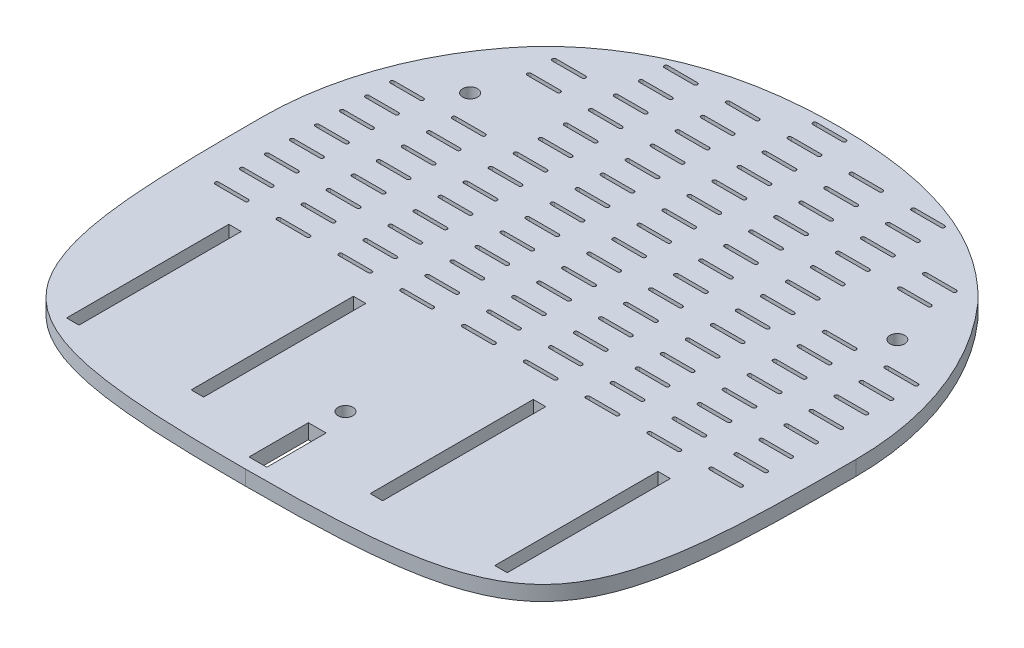
from build123d import *

# Parameters (mm, degrees)
BASE_DEPTH           = 6.35
EMPTYSPACETRIM_DEPTH = 185.858976792
SKETCH8_W            = 5.334
SKETCH8_H            = 69.446
SKETCH8_W_2          = 7.62
SKETCH8_H_2          = 25.4
SKETCH8_H_3          = 69.827
MOTORCUT_DEPTH       = 185.858976792
SKETCH11_R           = 3.175
SCREWCUT_DEPTH       = 185.858976792
CUT_EXTRUDE1_DEPTH   = 185.858976792
LPATTERN1_COUNT      = 9
LPATTERN1_PITCH      = 26.4541
LPATTERN1_COUNT_DIR2 = 15
LPATTERN1_PITCH_DIR2 = 10.7188


with BuildPart() as part:
    # Sketch1 → Base (new body)
    with BuildSketch(Plane(origin=(0, 0, 0), x_dir=(1, 0, 0), z_dir=(0, 1, 0))):
        with BuildLine():
            ThreePointArc((127, 0), (0, 127), (-127, 0))
            add(Edge.make_bspline(
                [(-127, 0), (-127, -50.624671912), (-125.847104384, -127.403215469), (-59.089145197, -134.177191606), (0, -134.177191606)],
                knots=[0, 0, 0, 0, 0.496988082, 1, 1, 1, 1], degree=3))
            add(Edge.make_bspline(
                [(127, 0), (127, -50.624671912), (125.847104384, -127.403215469), (59.089145197, -134.177191606), (0, -134.177191606)],
                knots=[0, 0, 0, 0, 0.496988082, 1, 1, 1, 1], degree=3))
        make_face()
    extrude(amount=BASE_DEPTH)

    # Sketch16 → EmptySpaceTrim (cut, through all)
    with BuildSketch(Plane(origin=(0, 6.35, 0), x_dir=(1, 0, 0), z_dir=(0, 1, 0))):
        with BuildLine():
            Line((-95.26964052, 133.35), (-95.26964052, 83.980328621))
            add(Edge.make_bspline(
                [(-95.26964052, 83.980328621), (-69.156047903, 111.711202419), (-34.972901221, 119.822808394), (0, 119.822808394)],
                knots=[0, 0, 0, 0, 1, 1, 1, 1], degree=3))
            add(Edge.make_bspline(
                [(95.26964052, 83.980328621), (69.156047903, 111.711202419), (34.972901221, 119.822808394), (0, 119.822808394)],
                knots=[0, 0, 0, 0, 1, 1, 1, 1], degree=3))
            Line((95.26964052, 83.980328621), (95.26964052, 133.35))
            Line((95.26964052, 133.35), (-95.26964052, 133.35))
        make_face()
    extrude(amount=-EMPTYSPACETRIM_DEPTH, mode=Mode.SUBTRACT)

    # Sketch8 → MotorCut (cut, through all)
    with BuildSketch(Plane(origin=(0, 6.35, 0), x_dir=(1, 0, 0), z_dir=(0, 1, 0))):
        with Locations((-38.378348141, -81.74)):
            Rectangle(SKETCH8_W, SKETCH8_H)
        with Locations((0, -116.230204152)):
            Rectangle(SKETCH8_W_2, SKETCH8_H_2)
        with Locations((-91.718348141, -81.74)):
            Rectangle(SKETCH8_W, SKETCH8_H)
        with Locations((91.718348141, -81.6765)):
            Rectangle(SKETCH8_W, SKETCH8_H_3)
        with Locations((38.378348141, -81.6765)):
            Rectangle(SKETCH8_W, SKETCH8_H_3)
    extrude(amount=-MOTORCUT_DEPTH, mode=Mode.SUBTRACT)

    # Sketch11 → ScrewCut (cut, through all)
    with BuildSketch(Plane(origin=(0, 6.35, 0), x_dir=(1, 0, 0), z_dir=(0, 1, 0))):
        with Locations(Location((0, -91.44, 0), (0, 0, 270))):
            Circle(SKETCH11_R)
        with Locations(Location((-91.44, 53.34, 0), (0, 0, 270))):
            Circle(SKETCH11_R)
        with Locations(Location((91.44, 53.34, 0), (0, 0, 90))):
            Circle(SKETCH11_R)
    extrude(amount=-SCREWCUT_DEPTH, mode=Mode.SUBTRACT)

    # Sketch17 → Cut-Extrude1 (cut, through all)
    with BuildSketch(Plane(origin=(0, 6.35, 0), x_dir=(1, 0, 0), z_dir=(0, 1, 0))):
        with BuildLine():
            Line((-112.165348141, -33.52325), (-99.465348141, -33.52325))
            ThreePointArc((-99.465348141, -33.52325), (-98.671598141, -34.317), (-99.465348141, -35.11075))
            Line((-99.465348141, -35.11075), (-112.165348141, -35.11075))
            ThreePointArc((-112.165348141, -35.11075), (-112.959098141, -34.317), (-112.165348141, -33.52325))
        make_face()
    cut_extrude1 = extrude(amount=-CUT_EXTRUDE1_DEPTH, mode=Mode.SUBTRACT)

    # LPattern1: Cut-Extrude1 9 × 15, 28 skipped
    with Locations(*[(i * LPATTERN1_PITCH, 0, -j * LPATTERN1_PITCH_DIR2) for i in range(LPATTERN1_COUNT) for j in range(LPATTERN1_COUNT_DIR2) if (i, j) not in ((0, 0), (0, 8), (0, 9), (0, 10), (0, 11), (0, 12), (0, 13), (0, 14), (1, 8), (1, 9), (1, 12), (1, 13), (1, 14), (2, 14), (3, 14), (5, 14), (6, 14), (7, 8), (7, 9), (7, 12), (7, 13), (7, 14), (8, 8), (8, 9), (8, 10), (8, 11), (8, 12), (8, 13), (8, 14))]):
        add(cut_extrude1, mode=Mode.SUBTRACT)


solid = part.part
